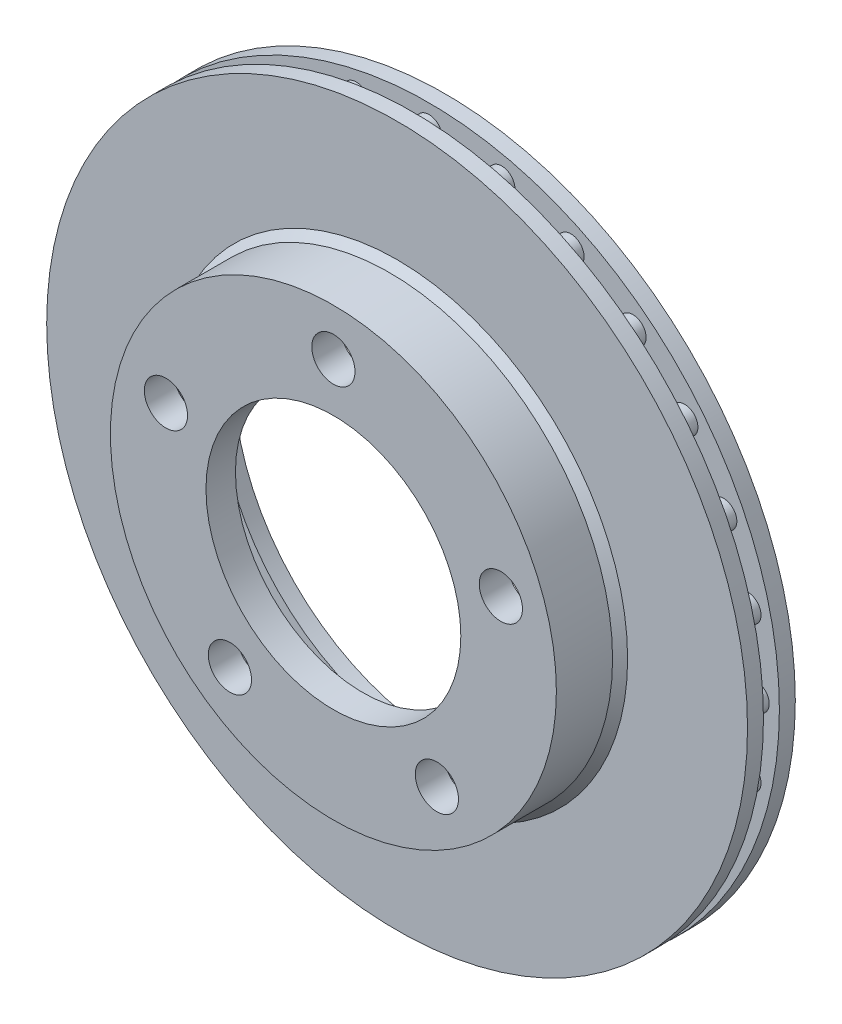
from build123d import *

# Parameters (mm, degrees)
SKETCH1_R          = 139.7
EXTRUDE4_DEPTH     = 6.35
SKETCH1_9_R        = 88.9
SKETCH1_9_R_2      = 8.613421261
SKETCH1_9_R_3      = 50.8
EXTRUDE5_DEPTH     = 25.4
CHAMFER1_SIZE      = 3
SKETCH2_R          = 84.244539411
CUT_EXTRUDE1_DEPTH = 20
EXTRUDE6_DEPTH     = 6.35
SKETCH4_R          = 139.7
SKETCH4_R_2        = 84.244539411
EXTRUDE7_DEPTH     = 6.35


with BuildPart() as part:
    # Sketch1 → Extrude4 (new body)
    with BuildSketch(Plane.XY):
        Circle(SKETCH1_R)
    extrude(amount=-EXTRUDE4_DEPTH)

    # Sketch1_9 → Extrude5 (add)
    with BuildSketch(Plane.XY):
        Circle(SKETCH1_9_R)
        with Locations((-66.756683218, 21.690561233)):
            Circle(SKETCH1_9_R_2, mode=Mode.SUBTRACT)
        with Locations((-41.257899205, -56.786626542)):
            Circle(SKETCH1_9_R_2, mode=Mode.SUBTRACT)
        with Locations((41.257899205, -56.786626542)):
            Circle(SKETCH1_9_R_2, mode=Mode.SUBTRACT)
        with Locations((66.756683218, 21.690561233)):
            Circle(SKETCH1_9_R_2, mode=Mode.SUBTRACT)
        with Locations((0, 70.192130619)):
            Circle(SKETCH1_9_R_2, mode=Mode.SUBTRACT)
        Circle(SKETCH1_9_R_3, mode=Mode.SUBTRACT)
    extrude(amount=EXTRUDE5_DEPTH)

    # Chamfer1
    chamfer1_edges = [part.edges().sort_by_distance(p)[0] for p in [
        (-88.9, 0, 0),
    ]]
    chamfer(chamfer1_edges, length=CHAMFER1_SIZE)

    # Sketch2 → Cut-Extrude1 (cut)
    with BuildSketch(Plane(origin=(0, 0, -6.35), x_dir=(-1, 0, 0), z_dir=(0, 0, -1))):
        Circle(SKETCH2_R)
    extrude(amount=-CUT_EXTRUDE1_DEPTH, mode=Mode.SUBTRACT)

    # Sketch3 → Extrude6 (add)
    with BuildSketch(Plane(origin=(0, 0, -6.35), x_dir=(-1, 0, 0), z_dir=(0, 0, -1))):
        with BuildLine():
            Line((5.30674264, 130.346866097), (5.30674264, 109.783238367))
            ThreePointArc((5.30674264, 109.783238367), (0, 104.476495726), (-5.30674264, 109.783238367))
            Line((-5.30674264, 109.783238367), (-5.30674264, 130.346866097))
            ThreePointArc((-5.30674264, 130.346866097), (0, 135.653608737), (5.30674264, 130.346866097))
        make_face()
        with BuildLine():
            Line((34.178597905, 125.897936695), (29.602760257, 105.849882045))
            ThreePointArc((29.602760257, 105.849882045), (23.248207406, 101.857051851), (19.255377212, 108.211604702))
            Line((19.255377212, 108.211604702), (23.83121486, 128.259659352))
            ThreePointArc((23.83121486, 128.259659352), (30.185767711, 132.252489546), (34.178597905, 125.897936695))
        make_face()
        with BuildLine():
            Line((61.336595553, 115.135959043), (52.414371864, 96.608770647))
            ThreePointArc((52.414371864, 96.608770647), (45.330652616, 94.130070077), (42.851952046, 101.213789325))
            Line((42.851952046, 101.213789325), (51.774175736, 119.740977721))
            ThreePointArc((51.774175736, 119.740977721), (58.857894984, 122.219678291), (61.336595553, 115.135959043))
        make_face()
        with BuildLine():
            Line((85.418920181, 98.600583638), (72.597708002, 82.523292085))
            ThreePointArc((72.597708002, 82.523292085), (65.140029619, 81.683013537), (64.299751071, 89.140691919))
            Line((64.299751071, 89.140691919), (77.12096325, 105.217983473))
            ThreePointArc((77.12096325, 105.217983473), (84.578641633, 106.058262021), (85.418920181, 98.600583638))
        make_face()
        with BuildLine():
            Line((105.217983473, 77.12096325), (89.140691919, 64.299751071))
            ThreePointArc((89.140691919, 64.299751071), (81.683013537, 65.140029619), (82.523292085, 72.597708002))
            Line((82.523292085, 72.597708002), (98.600583638, 85.418920181))
            ThreePointArc((98.600583638, 85.418920181), (106.058262021, 84.578641633), (105.217983473, 77.12096325))
        make_face()
        with BuildLine():
            Line((119.740977721, 51.774175736), (101.213789325, 42.851952046))
            ThreePointArc((101.213789325, 42.851952046), (94.130070077, 45.330652616), (96.608770647, 52.414371864))
            Line((96.608770647, 52.414371864), (115.135959043, 61.336595553))
            ThreePointArc((115.135959043, 61.336595553), (122.219678291, 58.857894984), (119.740977721, 51.774175736))
        make_face()
        with BuildLine():
            Line((128.259659352, 23.83121486), (108.211604702, 19.255377212))
            ThreePointArc((108.211604702, 19.255377212), (101.857051851, 23.248207406), (105.849882045, 29.602760257))
            Line((105.849882045, 29.602760257), (125.897936695, 34.178597905))
            ThreePointArc((125.897936695, 34.178597905), (132.252489546, 30.185767711), (128.259659352, 23.83121486))
        make_face()
        with BuildLine():
            Line((130.346866097, -5.30674264), (109.783238367, -5.30674264))
            ThreePointArc((109.783238367, -5.30674264), (104.476495726, 0), (109.783238367, 5.30674264))
            Line((109.783238367, 5.30674264), (130.346866097, 5.30674264))
            ThreePointArc((130.346866097, 5.30674264), (135.653608737, 0), (130.346866097, -5.30674264))
        make_face()
        with BuildLine():
            Line((125.897936695, -34.178597905), (105.849882045, -29.602760257))
            ThreePointArc((105.849882045, -29.602760257), (101.857051851, -23.248207406), (108.211604702, -19.255377212))
            Line((108.211604702, -19.255377212), (128.259659352, -23.83121486))
            ThreePointArc((128.259659352, -23.83121486), (132.252489546, -30.185767711), (125.897936695, -34.178597905))
        make_face()
        with BuildLine():
            Line((115.135959043, -61.336595553), (96.608770647, -52.414371864))
            ThreePointArc((96.608770647, -52.414371864), (94.130070077, -45.330652616), (101.213789325, -42.851952046))
            Line((101.213789325, -42.851952046), (119.740977721, -51.774175736))
            ThreePointArc((119.740977721, -51.774175736), (122.219678291, -58.857894984), (115.135959043, -61.336595553))
        make_face()
        with BuildLine():
            Line((98.600583638, -85.418920181), (82.523292085, -72.597708002))
            ThreePointArc((82.523292085, -72.597708002), (81.683013537, -65.140029619), (89.140691919, -64.299751071))
            Line((89.140691919, -64.299751071), (105.217983473, -77.12096325))
            ThreePointArc((105.217983473, -77.12096325), (106.058262021, -84.578641633), (98.600583638, -85.418920181))
        make_face()
        with BuildLine():
            Line((77.12096325, -105.217983473), (64.299751071, -89.140691919))
            ThreePointArc((64.299751071, -89.140691919), (65.140029619, -81.683013537), (72.597708002, -82.523292085))
            Line((72.597708002, -82.523292085), (85.418920181, -98.600583638))
            ThreePointArc((85.418920181, -98.600583638), (84.578641633, -106.058262021), (77.12096325, -105.217983473))
        make_face()
        with BuildLine():
            Line((51.774175736, -119.740977721), (42.851952046, -101.213789325))
            ThreePointArc((42.851952046, -101.213789325), (45.330652616, -94.130070077), (52.414371864, -96.608770647))
            Line((52.414371864, -96.608770647), (61.336595553, -115.135959043))
            ThreePointArc((61.336595553, -115.135959043), (58.857894984, -122.219678291), (51.774175736, -119.740977721))
        make_face()
        with BuildLine():
            Line((23.83121486, -128.259659352), (19.255377212, -108.211604702))
            ThreePointArc((19.255377212, -108.211604702), (23.248207406, -101.857051851), (29.602760257, -105.849882045))
            Line((29.602760257, -105.849882045), (34.178597905, -125.897936695))
            ThreePointArc((34.178597905, -125.897936695), (30.185767711, -132.252489546), (23.83121486, -128.259659352))
        make_face()
        with BuildLine():
            Line((-5.30674264, -130.346866097), (-5.30674264, -109.783238367))
            ThreePointArc((-5.30674264, -109.783238367), (0, -104.476495726), (5.30674264, -109.783238367))
            Line((5.30674264, -109.783238367), (5.30674264, -130.346866097))
            ThreePointArc((5.30674264, -130.346866097), (0, -135.653608737), (-5.30674264, -130.346866097))
        make_face()
        with BuildLine():
            Line((-34.178597905, -125.897936695), (-29.602760257, -105.849882045))
            ThreePointArc((-29.602760257, -105.849882045), (-23.248207406, -101.857051851), (-19.255377212, -108.211604702))
            Line((-19.255377212, -108.211604702), (-23.83121486, -128.259659352))
            ThreePointArc((-23.83121486, -128.259659352), (-30.185767711, -132.252489546), (-34.178597905, -125.897936695))
        make_face()
        with BuildLine():
            Line((-61.336595553, -115.135959043), (-52.414371864, -96.608770647))
            ThreePointArc((-52.414371864, -96.608770647), (-45.330652616, -94.130070077), (-42.851952046, -101.213789325))
            Line((-42.851952046, -101.213789325), (-51.774175736, -119.740977721))
            ThreePointArc((-51.774175736, -119.740977721), (-58.857894984, -122.219678291), (-61.336595553, -115.135959043))
        make_face()
        with BuildLine():
            Line((-85.418920181, -98.600583638), (-72.597708002, -82.523292085))
            ThreePointArc((-72.597708002, -82.523292085), (-65.140029619, -81.683013537), (-64.299751071, -89.140691919))
            Line((-64.299751071, -89.140691919), (-77.12096325, -105.217983473))
            ThreePointArc((-77.12096325, -105.217983473), (-84.578641633, -106.058262021), (-85.418920181, -98.600583638))
        make_face()
        with BuildLine():
            Line((-105.217983473, -77.12096325), (-89.140691919, -64.299751071))
            ThreePointArc((-89.140691919, -64.299751071), (-81.683013537, -65.140029619), (-82.523292085, -72.597708002))
            Line((-82.523292085, -72.597708002), (-98.600583638, -85.418920181))
            ThreePointArc((-98.600583638, -85.418920181), (-106.058262021, -84.578641633), (-105.217983473, -77.12096325))
        make_face()
        with BuildLine():
            Line((-119.740977721, -51.774175736), (-101.213789325, -42.851952046))
            ThreePointArc((-101.213789325, -42.851952046), (-94.130070077, -45.330652616), (-96.608770647, -52.414371864))
            Line((-96.608770647, -52.414371864), (-115.135959043, -61.336595553))
            ThreePointArc((-115.135959043, -61.336595553), (-122.219678291, -58.857894984), (-119.740977721, -51.774175736))
        make_face()
        with BuildLine():
            Line((-128.259659352, -23.83121486), (-108.211604702, -19.255377212))
            ThreePointArc((-108.211604702, -19.255377212), (-101.857051851, -23.248207406), (-105.849882045, -29.602760257))
            Line((-105.849882045, -29.602760257), (-125.897936695, -34.178597905))
            ThreePointArc((-125.897936695, -34.178597905), (-132.252489546, -30.185767711), (-128.259659352, -23.83121486))
        make_face()
        with BuildLine():
            Line((-130.346866097, 5.30674264), (-109.783238367, 5.30674264))
            ThreePointArc((-109.783238367, 5.30674264), (-104.476495726, 0), (-109.783238367, -5.30674264))
            Line((-109.783238367, -5.30674264), (-130.346866097, -5.30674264))
            ThreePointArc((-130.346866097, -5.30674264), (-135.653608737, 0), (-130.346866097, 5.30674264))
        make_face()
        with BuildLine():
            Line((-125.897936695, 34.178597905), (-105.849882045, 29.602760257))
            ThreePointArc((-105.849882045, 29.602760257), (-101.857051851, 23.248207406), (-108.211604702, 19.255377212))
            Line((-108.211604702, 19.255377212), (-128.259659352, 23.83121486))
            ThreePointArc((-128.259659352, 23.83121486), (-132.252489546, 30.185767711), (-125.897936695, 34.178597905))
        make_face()
        with BuildLine():
            Line((-115.135959043, 61.336595553), (-96.608770647, 52.414371864))
            ThreePointArc((-96.608770647, 52.414371864), (-94.130070077, 45.330652616), (-101.213789325, 42.851952046))
            Line((-101.213789325, 42.851952046), (-119.740977721, 51.774175736))
            ThreePointArc((-119.740977721, 51.774175736), (-122.219678291, 58.857894984), (-115.135959043, 61.336595553))
        make_face()
        with BuildLine():
            Line((-98.600583638, 85.418920181), (-82.523292085, 72.597708002))
            ThreePointArc((-82.523292085, 72.597708002), (-81.683013537, 65.140029619), (-89.140691919, 64.299751071))
            Line((-89.140691919, 64.299751071), (-105.217983473, 77.12096325))
            ThreePointArc((-105.217983473, 77.12096325), (-106.058262021, 84.578641633), (-98.600583638, 85.418920181))
        make_face()
        with BuildLine():
            Line((-77.12096325, 105.217983473), (-64.299751071, 89.140691919))
            ThreePointArc((-64.299751071, 89.140691919), (-65.140029619, 81.683013537), (-72.597708002, 82.523292085))
            Line((-72.597708002, 82.523292085), (-85.418920181, 98.600583638))
            ThreePointArc((-85.418920181, 98.600583638), (-84.578641633, 106.058262021), (-77.12096325, 105.217983473))
        make_face()
        with BuildLine():
            Line((-51.774175736, 119.740977721), (-42.851952046, 101.213789325))
            ThreePointArc((-42.851952046, 101.213789325), (-45.330652616, 94.130070077), (-52.414371864, 96.608770647))
            Line((-52.414371864, 96.608770647), (-61.336595553, 115.135959043))
            ThreePointArc((-61.336595553, 115.135959043), (-58.857894984, 122.219678291), (-51.774175736, 119.740977721))
        make_face()
        with BuildLine():
            Line((-23.83121486, 128.259659352), (-19.255377212, 108.211604702))
            ThreePointArc((-19.255377212, 108.211604702), (-23.248207406, 101.857051851), (-29.602760257, 105.849882045))
            Line((-29.602760257, 105.849882045), (-34.178597905, 125.897936695))
            ThreePointArc((-34.178597905, 125.897936695), (-30.185767711, 132.252489546), (-23.83121486, 128.259659352))
        make_face()
    extrude(amount=EXTRUDE6_DEPTH)

    # Sketch4 → Extrude7 (add)
    with BuildSketch(Plane(origin=(0, 0, -12.7), x_dir=(-1, 0, 0), z_dir=(0, 0, -1))):
        Circle(SKETCH4_R)
        Circle(SKETCH4_R_2, mode=Mode.SUBTRACT)
    extrude(amount=EXTRUDE7_DEPTH)


solid = part.part
